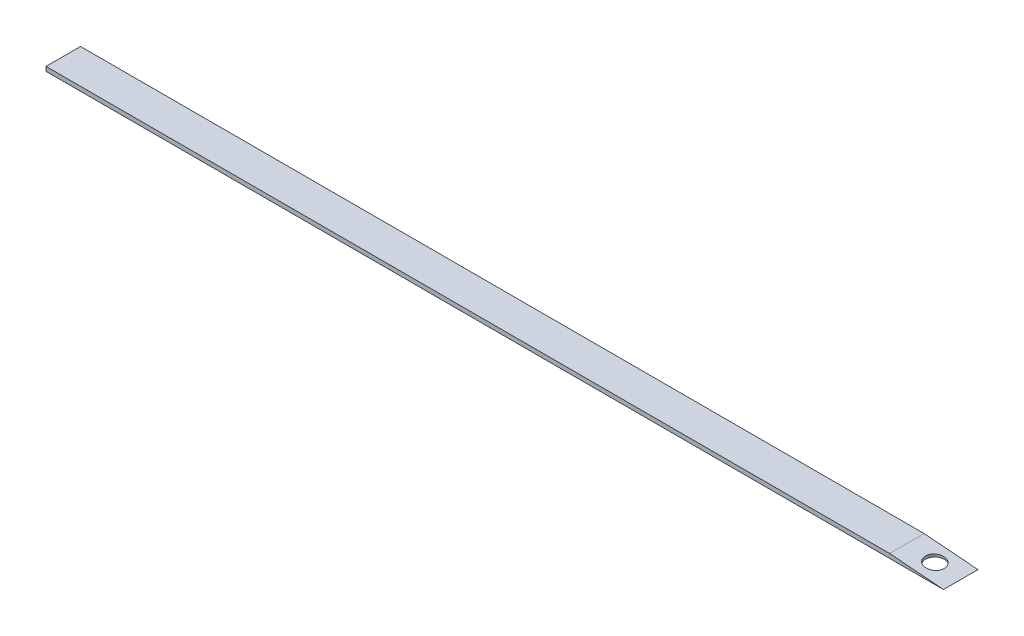
from build123d import *

# Parameters (mm, degrees)
SKETCH1_W               = 330.2
SKETCH1_H               = 12.7
SKETCH1_R               = 3.429
EXTRUDE1_DEPTH          = 1.5875
CUT_EXTRUDE2_DEPTH      = 7.35
CUT_EXTRUDE2_DEPTH_BACK = 7.35


with BuildPart() as part:
    # Sketch1 → Extrude1 (new body)
    with BuildSketch(Plane(origin=(0, 0, 0), x_dir=(1, 0, 0), z_dir=(0, 1, 0))):
        with Locations((165.1, 0)):
            Rectangle(SKETCH1_W, SKETCH1_H)
        with Locations(Location((320.675, 0, 0), (0, 0, 270))):  # turned: the seam where the file's is
            Circle(SKETCH1_R, mode=Mode.SUBTRACT)
    extrude(amount=EXTRUDE1_DEPTH)

    # Sketch2 → Cut-Extrude2 (cut, two sides)
    with BuildSketch(Plane.XY) as cut_extrude2_sk:
        Polygon((330.2, 0), (330.2, 2.264018557), (301.954487886, 2.264018557), align=None)
    extrude(amount=CUT_EXTRUDE2_DEPTH, mode=Mode.SUBTRACT)
    extrude(cut_extrude2_sk.sketch, amount=-CUT_EXTRUDE2_DEPTH_BACK, mode=Mode.SUBTRACT)


solid = part.part
